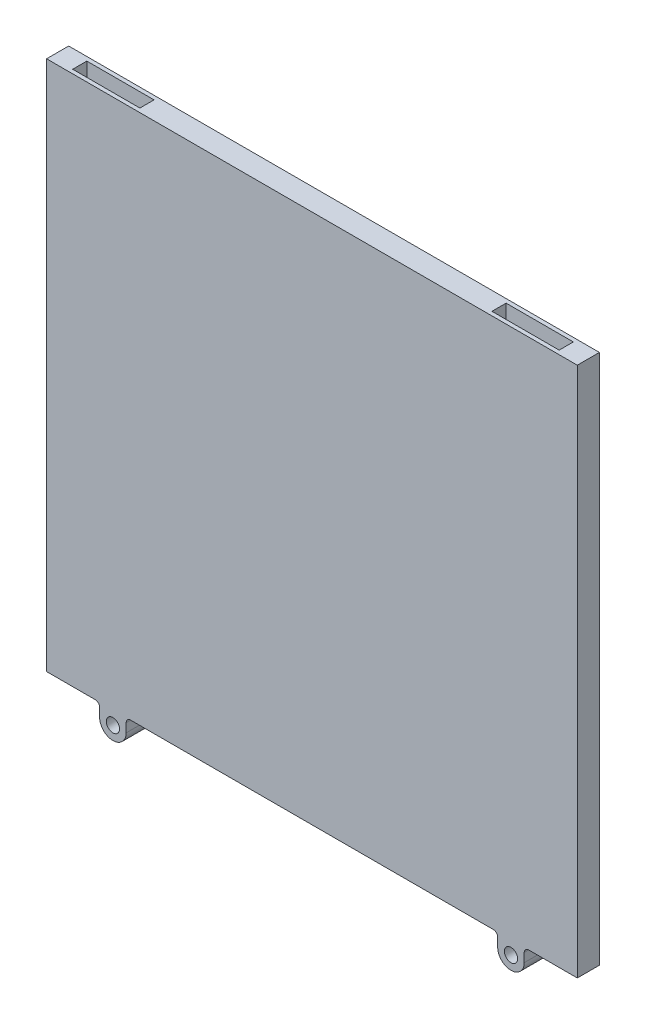
from build123d import *

# Parameters (mm, degrees)
SKETCH1_W            = 120
SKETCH1_H            = 120
BOSS_EXTRUDE1_DEPTH  = 2.5
SKETCH4_W            = 15.2
SKETCH4_H            = 3.2
CUT_EXTRUDE1_DEPTH   = 20
SKETCH6_R            = 1.5
BOSS_EXTRUDE2_DEPTH  = 5
FILLET1_R            = 1
FILLET1_OF_MIRROR1_R = 1


with BuildPart() as part:
    # Sketch1 → Boss-Extrude1 (new body, symmetric)
    with BuildSketch(Plane.XY):
        Rectangle(SKETCH1_W, SKETCH1_H)
    extrude(amount=BOSS_EXTRUDE1_DEPTH, both=True)

    # Sketch4 → Cut-Extrude1 (cut)
    with BuildSketch(Plane(origin=(0, 60, 0), x_dir=(1, 0, 0), z_dir=(0, 1, 0))):
        with Locations((-47.4, 0)):
            Rectangle(SKETCH4_W, SKETCH4_H)
        with Locations((47.4, 0)):
            Rectangle(SKETCH4_W, SKETCH4_H)
    extrude(amount=-CUT_EXTRUDE1_DEPTH, mode=Mode.SUBTRACT)

    # Sketch6 → Boss-Extrude2 (add)
    with BuildSketch(Plane.XY.offset(2.5)):
        with BuildLine():
            Line((42, -60), (48, -60))
            Line((48, -60), (48, -63))
            ThreePointArc((48, -63), (45, -66), (42, -63))
            Line((42, -63), (42, -60))
        make_face()
        with Locations((45, -63)):
            Circle(SKETCH6_R, mode=Mode.SUBTRACT)
    boss_extrude2 = extrude(amount=-BOSS_EXTRUDE2_DEPTH)

    # Fillet1
    fillet1_edges = [part.edges().sort_by_distance(p)[0] for p in [
        (42, -60, 0),
        (48, -60, 0),
    ]]
    fillet(fillet1_edges, radius=FILLET1_R)

    # Mirror1: Boss-Extrude2 across plane
    add(boss_extrude2.mirror(Plane(origin=(0, 0, 0), x_dir=(0, 0, 1), z_dir=(1, 0, 0))))

    # Fillet1 of Mirror1
    fillet1_of_mirror1_edges = [part.edges().sort_by_distance(p)[0] for p in [
        (-42, -60, 0),
        (-48, -60, 0),
    ]]
    fillet(fillet1_of_mirror1_edges, radius=FILLET1_OF_MIRROR1_R)


solid = part.part
